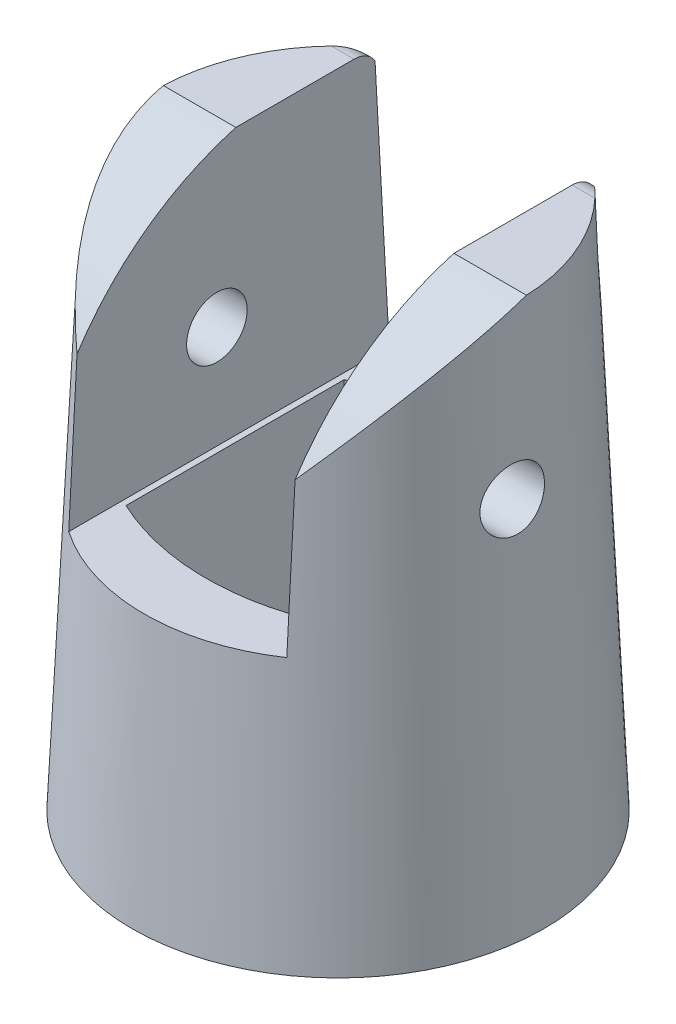
from build123d import *

# Parameters (mm, degrees)
SKETCH2_R               = 7.5
SKETCH3_R               = 8.5
SKETCH9_W               = 8.5
SKETCH9_H               = 24.609106297
CUT_EXTRUDE1_DEPTH      = 10
CUT_EXTRUDE1_DEPTH_BACK = 10
CUT_EXTRUDE2_DEPTH      = 10
CUT_EXTRUDE2_DEPTH_BACK = 10
CUT_EXTRUDE3_DEPTH      = 14
FILLET1_R               = 1
SKETCH12_R              = 1.25
CUT_EXTRUDE4_DEPTH      = 9
SKETCH13_W              = 23.915036099
SKETCH13_H              = 16.531080044
CUT_EXTRUDE5_DEPTH      = 4.5


with BuildPart() as part:
    # Sketch2 → Loft1 section 0
    with BuildSketch(Plane(origin=(0, 22, 0), x_dir=(1, 0, 0), z_dir=(0, 1, 0))):
        Circle(SKETCH2_R)
    # Sketch3 → Loft1 section 1
    with BuildSketch(Plane(origin=(0, 0, 0), x_dir=(1, 0, 0), z_dir=(0, 1, 0))):
        Circle(SKETCH3_R)
    loft()

    # Sketch9 → Cut-Extrude1 (cut, two sides)
    with BuildSketch(Plane.XY) as cut_extrude1_sk:
        with Locations((0, 23.304553149)):
            Rectangle(SKETCH9_W, SKETCH9_H)
    extrude(amount=CUT_EXTRUDE1_DEPTH, mode=Mode.SUBTRACT)
    extrude(cut_extrude1_sk.sketch, amount=-CUT_EXTRUDE1_DEPTH_BACK, mode=Mode.SUBTRACT)

    # Sketch10 → Cut-Extrude2 (cut, two sides)
    with BuildSketch(Plane(origin=(0, 0, 0), x_dir=(0, 0, -1), z_dir=(1, 0, 0))) as cut_extrude2_sk:
        with BuildLine():
            ThreePointArc((1.551397817, 22.278129211), (-3.230375863, 20.336914385), (-6.681717999, 16.5))
            Line((-6.681717999, 16.5), (-6.777720856, 11))
            Line((-6.777720856, 11), (-14.541953313, 11))
            Line((-14.541953313, 11), (-14.541953313, 25.761445422))
            Line((-14.541953313, 25.761445422), (14.965624753, 25.761445422))
            Line((14.965624753, 25.761445422), (14.965624753, 11))
            Line((14.965624753, 11), (6.777720856, 11))
            Line((6.777720856, 11), (6.043769414, 23))
            Line((6.043769414, 23), (1.551397817, 22.278129211))
        make_face()
    extrude(amount=CUT_EXTRUDE2_DEPTH, mode=Mode.SUBTRACT)
    extrude(cut_extrude2_sk.sketch, amount=-CUT_EXTRUDE2_DEPTH_BACK, mode=Mode.SUBTRACT)

    # Sketch11 → Cut-Extrude3 (cut)
    with BuildSketch(Plane(origin=(0, 0, 0), x_dir=(-1, 0, 0), z_dir=(0, -1, 0))):
        with BuildLine():
            Line((4.25, -4.5), (4.25, 4.5))
            ThreePointArc((4.25, 4.5), (0, 5.448066505), (-4.25, 4.5))
            Line((-4.25, 4.5), (-4.25, -4.5))
            ThreePointArc((-4.25, -4.5), (0, -5.448066505), (4.25, -4.5))
        make_face()
    extrude(amount=-CUT_EXTRUDE3_DEPTH, mode=Mode.SUBTRACT)

    # Fillet1
    fillet1_edges = [part.edges().sort_by_distance(p)[0] for p in [
        (4.303290893, 22, -6.104932034),
        (-4.303290893, 22, -6.104932034),
    ]]
    fillet(fillet1_edges, radius=FILLET1_R)

    # Sketch12 → Cut-Extrude4 (cut, symmetric)
    with BuildSketch(Plane(origin=(0, 0, 0), x_dir=(0, 0, -1), z_dir=(1, 0, 0))):
        with Locations((-0.5, 15.25)):
            Circle(SKETCH12_R)
    extrude(amount=CUT_EXTRUDE4_DEPTH, both=True, mode=Mode.SUBTRACT)

    # Sketch13 → Cut-Extrude5 (cut, symmetric)
    with BuildSketch(Plane(origin=(0, 0, 0), x_dir=(0, 0, -1), z_dir=(1, 0, 0))):
        with Locations((-0.392988947, 19.265540022)):
            Rectangle(SKETCH13_W, SKETCH13_H)
    extrude(amount=CUT_EXTRUDE5_DEPTH, both=True, mode=Mode.SUBTRACT)


solid = part.part
